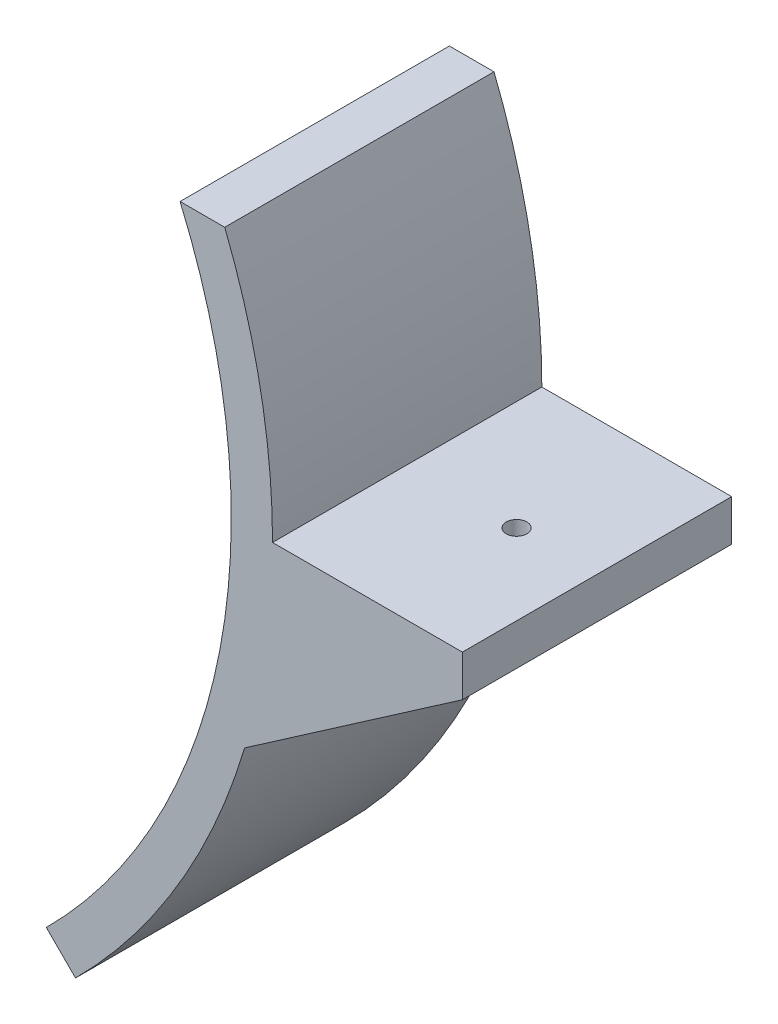
from build123d import *

# Parameters (mm, degrees)
SALIENTE_EXTRUIR1_DEPTH = 65.25
CROQUIS3_W              = 45.25
CROQUIS3_H              = 36.500322872
CORTAR_EXTRUIR1_DEPTH   = 45
CROQUIS5_R              = 2.5
CORTAR_EXTRUIR3_DEPTH   = 45
CROQUIS9_R              = 2.5
CORTAR_EXTRUIR5_DEPTH   = 45


with BuildPart() as part:
    # Croquis1 → Saliente-Extruir1 (new body)
    with BuildSketch(Plane.XY):
        with BuildLine():
            Line((209, 0), (163, 0))
            ThreePointArc((163, 0), (160.07788224, 30.725748448), (151.41629917, 60.349849592))
            Line((151.41629917, 60.349849592), (140.594792415, 60.349849592))
            ThreePointArc((140.594792415, 60.349849592), (150.24757204, -28.890605671), (108.187337522, -108.187337522))
            Line((108.187337522, -108.187337522), (115.258405333, -115.258405333))
            ThreePointArc((115.258405333, -115.258405333), (140.028326503, -83.43301371), (156.226502146, -46.500322872))
            Line((156.226502146, -46.500322872), (209, -10))
            Line((209, -10), (209, 0))
        make_face()
    extrude(amount=SALIENTE_EXTRUIR1_DEPTH)

    # Croquis3 → Cortar-Extruir1 (cut)
    with BuildSketch(Plane(origin=(209, 0, 0), x_dir=(0, 0, -1), z_dir=(1, 0, 0))):
        with Locations((-32.625, -28.250161436)):
            Rectangle(CROQUIS3_W, CROQUIS3_H)
    extrude(amount=-CORTAR_EXTRUIR1_DEPTH, mode=Mode.SUBTRACT)

    # Croquis5 → Cortar-Extruir3 (cut)
    with BuildSketch(Plane(origin=(10, 0, 0), x_dir=(0, 0, -1), z_dir=(1, 0, 0))):
        with Locations((-32.625, -172.846481178)):
            Circle(CROQUIS5_R)
    extrude(amount=-CORTAR_EXTRUIR3_DEPTH, mode=Mode.SUBTRACT)

    # Croquis9 → Cortar-Extruir5 (cut)
    with BuildSketch(Plane(origin=(0, -10, 0), x_dir=(-1, 0, 0), z_dir=(0, -1, 0))):
        with Locations((-189.5, -32.625)):
            Circle(CROQUIS9_R)
    extrude(amount=-CORTAR_EXTRUIR5_DEPTH, mode=Mode.SUBTRACT)


solid = part.part
